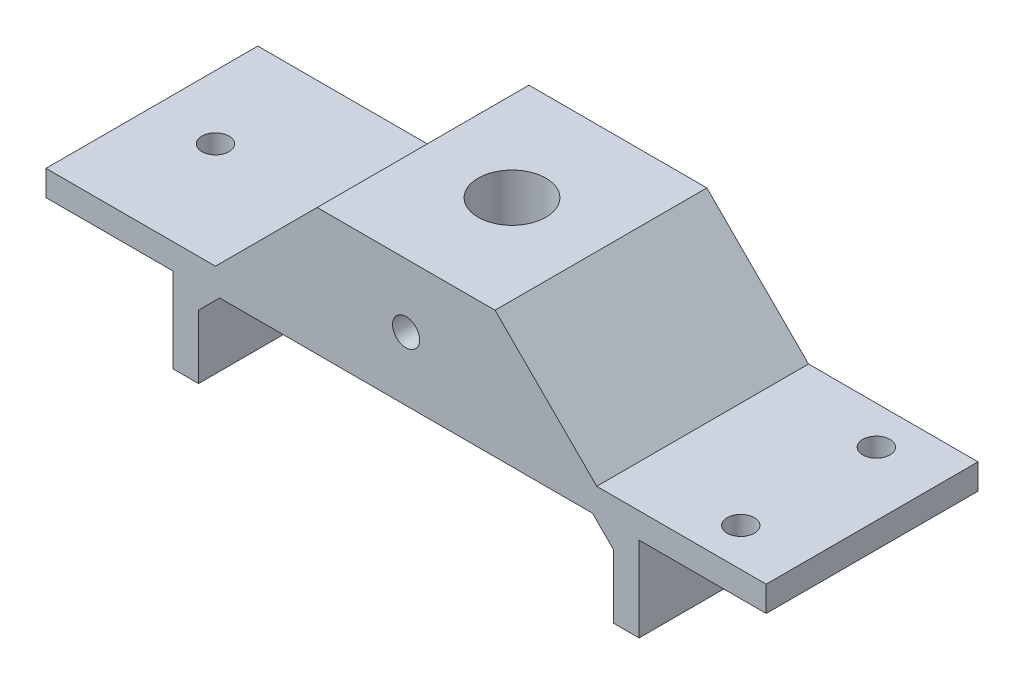
from build123d import *

# Parameters (mm, degrees)
SKETCH_1_W          = 85
SKETCH_1_H          = 3
EXTRUDE_1_DEPTH     = 25
SKETCH_2_W          = 3
SKETCH_2_H          = 25
EXTRUDE_2_DEPTH     = 10
SKETCH_3_W          = 3
SKETCH_3_H          = 25
EXTRUDE_3_DEPTH     = 10
SKETCH_4_W          = 25
SKETCH_4_H          = 25
EXTRUDE_1_2_DEPTH   = 12
CUT_EXTRUDE_1_REACH = 27
SKETCH_5_R          = 4
CHAMFER_1_SIZE      = 10
CHAMFER_2_SIZE      = 10
CUT_EXTRUDE_3_REACH = 27
CUT_EXTRUDE_4_REACH = 17
SKETCH_8_R          = 1.6
CHAMFER_4_SIZE      = 2.5
CHAMFER_5_SIZE      = 2.5
SKETCH_9_R          = 1.6
CUT_EXTRUDE_5_DEPTH = 25


with BuildPart() as part:
    # 草图1 → Extrude 1 (new body)
    with BuildSketch(Plane.XY):
        with Locations((0, -1.5)):
            Rectangle(SKETCH_1_W, SKETCH_1_H)
    extrude(amount=EXTRUDE_1_DEPTH)

    # 草图2 → 拉伸-薄壁2 (add)
    with BuildSketch(Plane.XZ.offset(3)):
        with Locations((-26, 12.5)):
            Rectangle(SKETCH_2_W, SKETCH_2_H)
    extrude(amount=EXTRUDE_2_DEPTH)

    # 草图3 → 拉伸-薄壁3 (add)
    with BuildSketch(Plane.XZ.offset(3)):
        with Locations((26, 12.5)):
            Rectangle(SKETCH_3_W, SKETCH_3_H)
    extrude(amount=EXTRUDE_3_DEPTH)

    # 草图4 → Extrude 1 2 (add)
    with BuildSketch(Plane(origin=(0, 0, 0), x_dir=(1, 0, 0), z_dir=(0, 1, 0))):
        with Locations((0, -12.5)):
            Rectangle(SKETCH_4_W, SKETCH_4_H)
    extrude(amount=EXTRUDE_1_2_DEPTH)

    # 草图5 → 切除-拉伸1 (cut, up to next)
    with BuildSketch(Plane(origin=(0, 12, 0), x_dir=(1, 0, 0), z_dir=(0, 1, 0)), mode=Mode.PRIVATE) as cut_extrude_1_sk1:
        with Locations((0, -12.5)):
            Circle(SKETCH_5_R)
    cut_extrude_1_tool1 = extrude(cut_extrude_1_sk1.sketch, amount=-CUT_EXTRUDE_1_REACH, mode=Mode.PRIVATE) & part.part
    add(cut_extrude_1_tool1.solids().sort_by_distance((0, 12, 12.5))[0], mode=Mode.SUBTRACT)

    # 倒角1
    chamfer_1_edges = [part.edges().sort_by_distance(p)[0] for p in [
        (12.5, 0, 12.5),
    ]]
    chamfer(chamfer_1_edges, length=CHAMFER_1_SIZE)

    # 倒角2
    chamfer_2_edges = [part.edges().sort_by_distance(p)[0] for p in [
        (-12.5, 0, 12.5),
    ]]
    chamfer(chamfer_2_edges, length=CHAMFER_2_SIZE)

    # 草图7 → 切除-拉伸3 (cut, up to next)
    with BuildSketch(Plane(origin=(0, 0, 0), x_dir=(-1, 0, 0), z_dir=(0, 0, -1)), mode=Mode.PRIVATE) as cut_extrude_3_sk1:
        Polygon((-12.5, 10), (-10.5, 12), (-12.5, 12), align=None)
    cut_extrude_3_tool1 = extrude(cut_extrude_3_sk1.sketch, amount=-CUT_EXTRUDE_3_REACH, mode=Mode.PRIVATE) & part.part
    add(cut_extrude_3_tool1.solids().sort_by_distance((11.833333, 11.333333, 0))[0], mode=Mode.SUBTRACT)
    # 草图7 → 切除-拉伸3 (cut, up to next)
    with BuildSketch(Plane(origin=(0, 0, 0), x_dir=(-1, 0, 0), z_dir=(0, 0, -1)), mode=Mode.PRIVATE) as cut_extrude_3_sk2:
        Polygon((12.5, 10), (10.5, 12), (12.5, 12), align=None)
    cut_extrude_3_tool2 = extrude(cut_extrude_3_sk2.sketch, amount=-CUT_EXTRUDE_3_REACH, mode=Mode.PRIVATE) & part.part
    add(cut_extrude_3_tool2.solids().sort_by_distance((-11.833333, 11.333333, 0))[0], mode=Mode.SUBTRACT)

    # 草图8 → 切除-拉伸4 (cut, up to next)
    with BuildSketch(Plane.XZ.offset(3), mode=Mode.PRIVATE) as cut_extrude_4_sk1:
        with Locations((35, 4.5)):
            Circle(SKETCH_8_R)
    cut_extrude_4_tool1 = extrude(cut_extrude_4_sk1.sketch, amount=-CUT_EXTRUDE_4_REACH, mode=Mode.PRIVATE) & part.part
    add(cut_extrude_4_tool1.solids().sort_by_distance((35, -3, 4.5))[0], mode=Mode.SUBTRACT)
    # 草图8 → 切除-拉伸4 (cut, up to next)
    with BuildSketch(Plane.XZ.offset(3), mode=Mode.PRIVATE) as cut_extrude_4_sk2:
        with Locations((35, 20.5)):
            Circle(SKETCH_8_R)
    cut_extrude_4_tool2 = extrude(cut_extrude_4_sk2.sketch, amount=-CUT_EXTRUDE_4_REACH, mode=Mode.PRIVATE) & part.part
    add(cut_extrude_4_tool2.solids().sort_by_distance((35, -3, 20.5))[0], mode=Mode.SUBTRACT)
    # 草图8 → 切除-拉伸4 (cut, up to next)
    with BuildSketch(Plane.XZ.offset(3), mode=Mode.PRIVATE) as cut_extrude_4_sk3:
        with Locations((-35, 12.5)):
            Circle(SKETCH_8_R)
    cut_extrude_4_tool3 = extrude(cut_extrude_4_sk3.sketch, amount=-CUT_EXTRUDE_4_REACH, mode=Mode.PRIVATE) & part.part
    add(cut_extrude_4_tool3.solids().sort_by_distance((-35, -3, 12.5))[0], mode=Mode.SUBTRACT)

    # 倒角4
    chamfer_4_edges = [part.edges().sort_by_distance(p)[0] for p in [
        (24.5, -3, 12.5),
    ]]
    chamfer(chamfer_4_edges, length=CHAMFER_4_SIZE)

    # 倒角5
    chamfer_5_edges = [part.edges().sort_by_distance(p)[0] for p in [
        (-24.5, -3, 12.5),
    ]]
    chamfer(chamfer_5_edges, length=CHAMFER_5_SIZE)

    # 草图9 → 切除-拉伸5 (cut)
    with BuildSketch(Plane.XY.offset(25)):
        with Locations((0, 4.5)):
            Circle(SKETCH_9_R)
    extrude(amount=-CUT_EXTRUDE_5_DEPTH, mode=Mode.SUBTRACT)


solid = part.part
